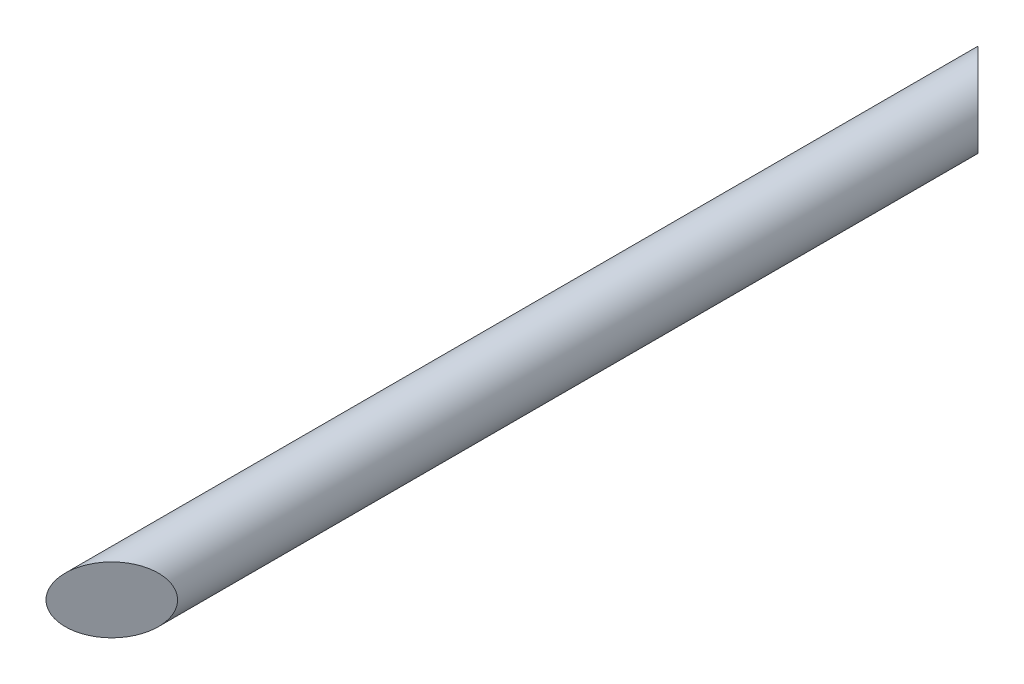
from build123d import *

# Parameters (mm, degrees)
SKETCH1_R           = 30
BOSS_EXTRUDE2_DEPTH = 850
CUT_EXTRUDE1_DEPTH  = 70
CUT_EXTRUDE2_DEPTH  = 70


with BuildPart() as part:
    # Sketch1 → Boss-Extrude2 (new body)
    with BuildSketch(Plane.XY):
        Circle(SKETCH1_R)
    extrude(amount=BOSS_EXTRUDE2_DEPTH)

    # Sketch4 → Cut-Extrude1 (cut)
    with BuildSketch(Plane(origin=(0, 40, 0), x_dir=(1, 0, 0), z_dir=(0, 1, 0))):
        Polygon((-30, -850), (30, -850), (30, -790), align=None)
    extrude(amount=-CUT_EXTRUDE1_DEPTH, mode=Mode.SUBTRACT)

    # Sketch3 → Cut-Extrude2 (cut)
    with BuildSketch(Plane(origin=(0, 40, 0), x_dir=(1, 0, 0), z_dir=(0, 1, 0))):
        Polygon((-30, 0), (30, -60), (30, 0), align=None)
    extrude(amount=-CUT_EXTRUDE2_DEPTH, mode=Mode.SUBTRACT)


solid = part.part
